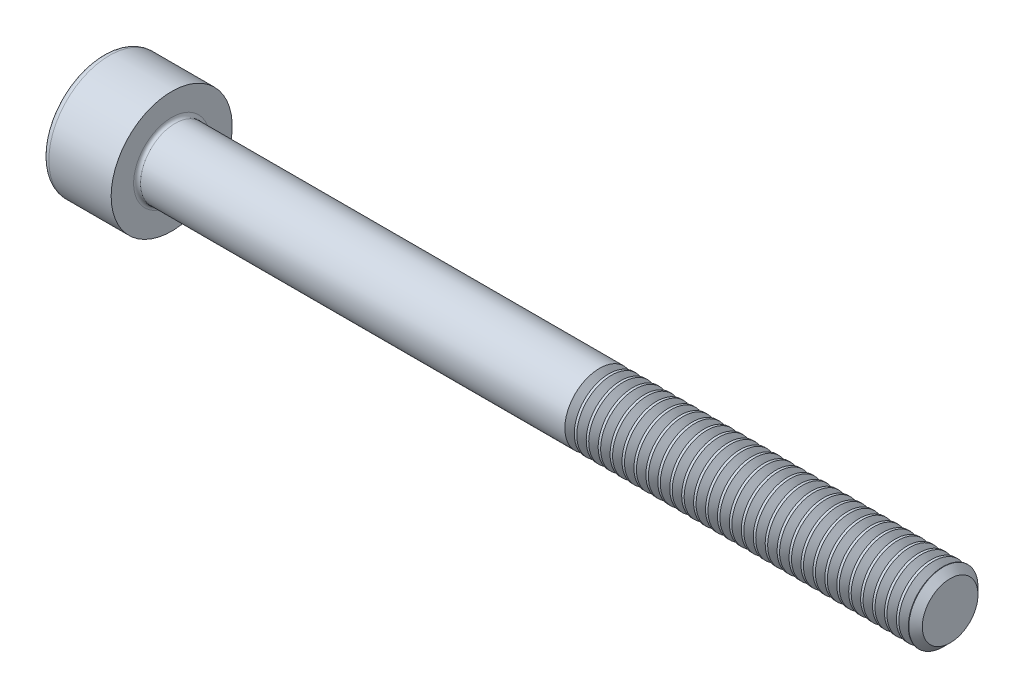
from build123d import *

# Parameters (mm, degrees)
FILLET1_R       = 0.2
FILLET2_R       = 0.4
HEX_2_DEPTH     = 2
THDSCHPAT_COUNT = 29
THDSCHPAT_PITCH = 0.689655172


with BuildPart() as part:
    # BodySke → Base-Revolve (revolve)
    with BuildSketch(Plane.XY, mode=Mode.PRIVATE) as base_revolve_sk:
        Polygon((0, 0), (0, 3.5), (4, 3.5), (4, 2), (48.61, 2), (49, 1.61), (49, 0), align=None)
    revolve(base_revolve_sk.sketch.rotate(Axis((-31.75, 0, 0), (1, 0, 0)), 90), axis=Axis((-31.75, 0, 0), (1, 0, 0)))  # turned: the seam where the file's is

    # Fillet1
    fillet1_edges = [part.edges().sort_by_distance(p)[0] for p in [
        (4, 0, -2),
    ]]
    fillet(fillet1_edges, radius=FILLET1_R)

    # Fillet2
    fillet2_edges = [part.edges().sort_by_distance(p)[0] for p in [
        (0, 0, -3.5),
    ]]
    fillet(fillet2_edges, radius=FILLET2_R)

    # Sketch2 → Hex-PreBroach (revolve, cut)
    with BuildSketch(Plane.XY, mode=Mode.PRIVATE) as hex_prebroach_sk:
        Polygon((0, 1.51), (2, 1.51), (2.871798906, 0), (0, 0), align=None)
    revolve(hex_prebroach_sk.sketch.rotate(Axis((0, 0, 0), (1, 0, 0)), 90), axis=Axis((0, 0, 0), (1, 0, 0)), mode=Mode.SUBTRACT)  # turned: the seam where the file's is

    # Sketch3 → Hex 2 (cut)
    with BuildSketch(Plane(origin=(0, 0, 0), x_dir=(0, 0.5, 0.866025404), z_dir=(-1, 0, 0))):
        Polygon((0.871798906, 1.51), (-0.871798906, 1.51), (-1.743597813, 0), (-0.871798906, -1.51), (0.871798906, -1.51), (1.743597813, 0), align=None)
    extrude(amount=-HEX_2_DEPTH, mode=Mode.SUBTRACT)

    # ThdSchSke → ThreadSchematic (revolve, cut)
    with BuildSketch(Plane.XY, mode=Mode.PRIVATE) as threadschematic_sk:
        Polygon((29, -1.61), (28.72691906, -2), (28.72691906, -2.5), (29.27308094, -2.5), (29.27308094, -2), align=None)
    threadschematic = revolve(threadschematic_sk.sketch.rotate(Axis((-3.175, 0, 0), (1, 0, 0)), 270), axis=Axis((-3.175, 0, 0), (1, 0, 0)), mode=Mode.SUBTRACT)  # turned: the seam where the file's is

    # ThdSchPat: ThreadSchematic ×29
    with Locations(*[(i * THDSCHPAT_PITCH, 0, 0) for i in range(1, THDSCHPAT_COUNT)]):
        add(threadschematic, mode=Mode.SUBTRACT)


solid = part.part
